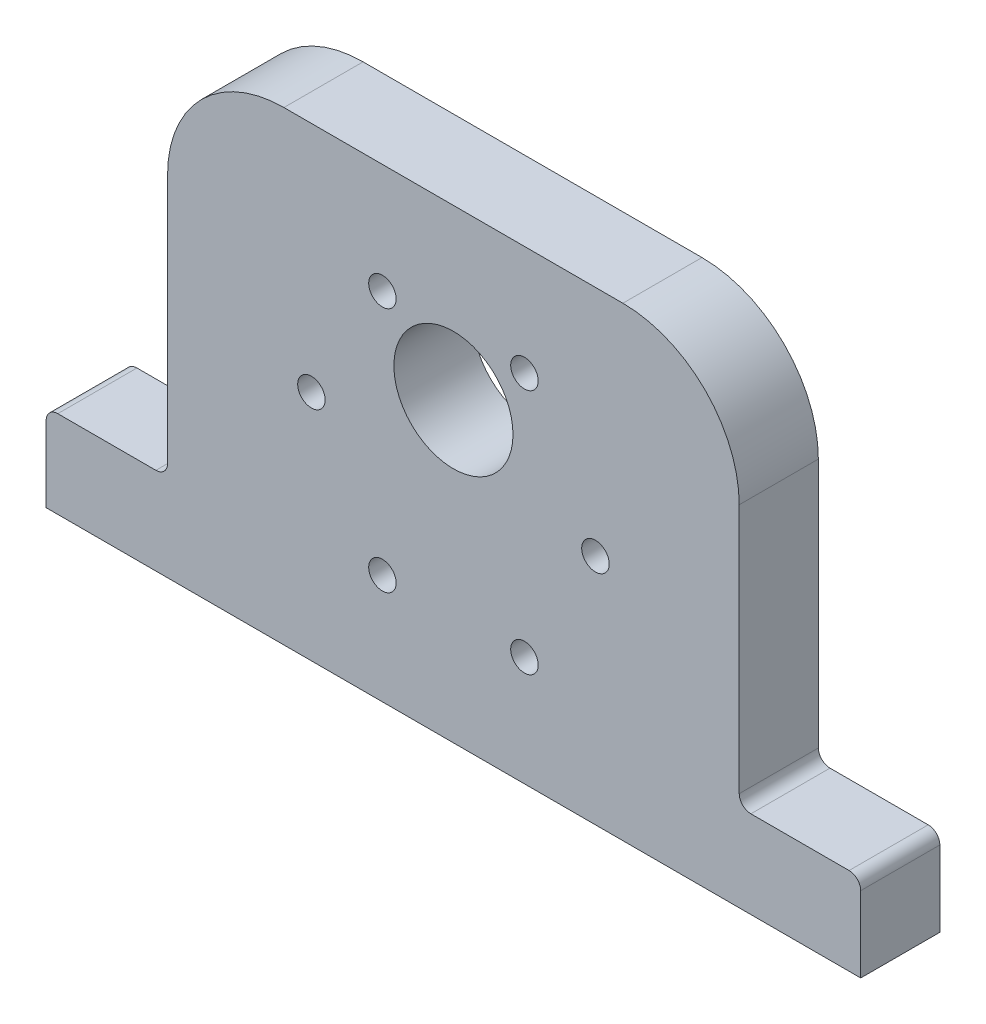
from build123d import *

# Parameters (mm, degrees)
SKETCH1_R           = 6.5
SKETCH1_R_2         = 1.5
BOSS_EXTRUDE1_DEPTH = 8.636
FILLET1_R           = 12.7
FILLET2_R           = 1.27


with BuildPart() as part:
    # Sketch1 → Boss-Extrude1 (new body)
    with BuildSketch(Plane.XY):
        Polygon((0, 0), (88.9, 0), (88.9, 9.525), (75.6412, 9.525), (75.6412, 50.8), (13.25, 50.8), (13.25, 9.525), (0, 9.525), align=None)
        with Locations((44.45, 32.4)):
            Circle(SKETCH1_R, mode=Mode.SUBTRACT)
        with Locations((28.95, 25.4)):
            Circle(SKETCH1_R_2, mode=Mode.SUBTRACT)
        with Locations((59.95, 25.4)):
            Circle(SKETCH1_R_2, mode=Mode.SUBTRACT)
        with Locations((52.2, 11.976606241)):
            Circle(SKETCH1_R_2, mode=Mode.SUBTRACT)
        with Locations((36.7, 11.976606241)):
            Circle(SKETCH1_R_2, mode=Mode.SUBTRACT)
        with Locations((36.7, 38.823393759)):
            Circle(SKETCH1_R_2, mode=Mode.SUBTRACT)
        with Locations((52.2, 38.823393759)):
            Circle(SKETCH1_R_2, mode=Mode.SUBTRACT)
    extrude(amount=BOSS_EXTRUDE1_DEPTH)

    # Fillet1
    fillet1_edges = [part.edges().sort_by_distance(p)[0] for p in [
        (13.25, 50.8, 4.318),
        (75.6412, 50.8, 4.318),
    ]]
    fillet(fillet1_edges, radius=FILLET1_R)

    # Fillet2
    fillet2_edges = [part.edges().sort_by_distance(p)[0] for p in [
        (0, 9.525, 4.318),
        (13.25, 9.525, 4.318),
        (75.6412, 9.525, 4.318),
        (88.9, 9.525, 4.318),
    ]]
    fillet(fillet2_edges, radius=FILLET2_R)


solid = part.part
